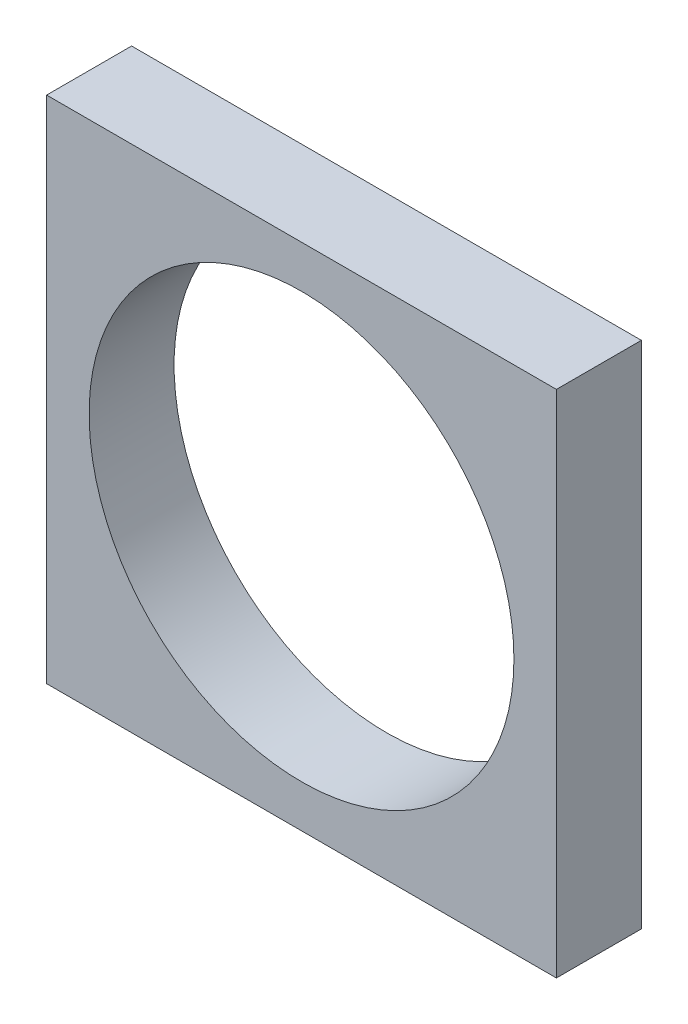
from build123d import *

# Parameters (mm, degrees)
SCHIZZO1_W                   = 60
SCHIZZO1_H                   = 60
SCHIZZO1_R                   = 25
ESTRUSIONE_ESTRUSIONE2_DEPTH = 10


with BuildPart() as part:
    # Schizzo1 → Estrusione-Estrusione2 (new body)
    with BuildSketch(Plane.XY):
        Rectangle(SCHIZZO1_W, SCHIZZO1_H)
        Circle(SCHIZZO1_R, mode=Mode.SUBTRACT)
    extrude(amount=ESTRUSIONE_ESTRUSIONE2_DEPTH)


solid = part.part
